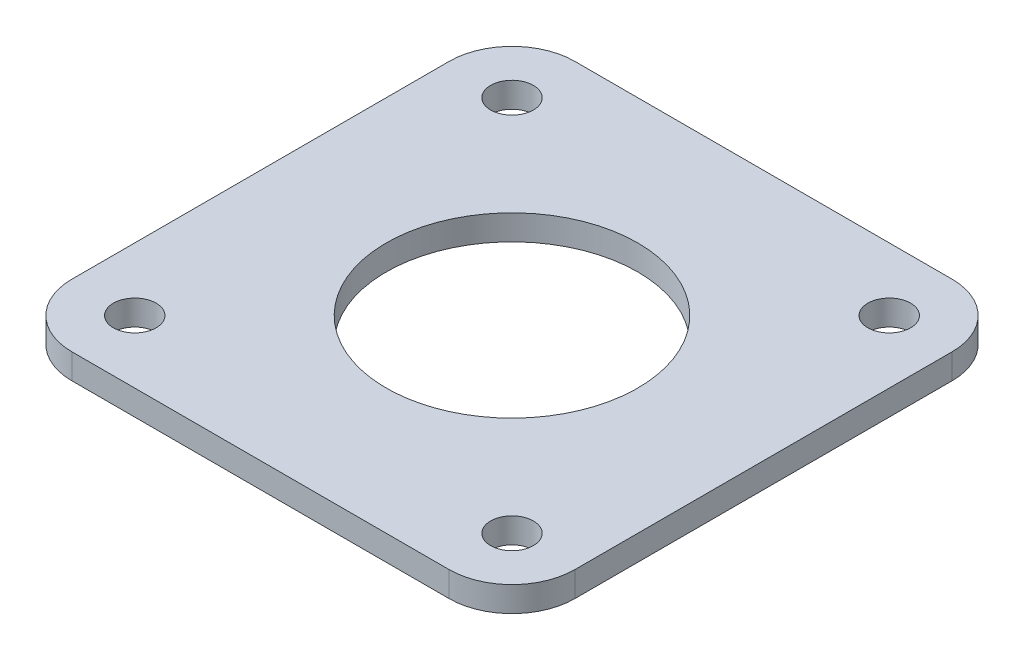
from build123d import *

# Parameters (mm, degrees)
SKETCH1_R           = 1.7
SKETCH1_R_2         = 10
BOSS_EXTRUDE1_DEPTH = 2


with BuildPart() as part:
    # Sketch1 → Boss-Extrude1 (new body)
    with BuildSketch(Plane.XZ.offset(3)):
        with BuildLine():
            Line((-15, -20), (15, -20))
            ThreePointArc((15, -20), (18.535533906, -18.535533906), (20, -15))
            Line((20, -15), (20, 15))
            ThreePointArc((20, 15), (18.535533906, 18.535533906), (15, 20))
            Line((15, 20), (-15, 20))
            ThreePointArc((-15, 20), (-18.535533906, 18.535533906), (-20, 15))
            Line((-20, 15), (-20, -15))
            ThreePointArc((-20, -15), (-18.535533906, -18.535533906), (-15, -20))
        make_face()
        with Locations((15, -15)):
            Circle(SKETCH1_R, mode=Mode.SUBTRACT)
        with Locations((-15, -15)):
            Circle(SKETCH1_R, mode=Mode.SUBTRACT)
        with Locations((15, 15)):
            Circle(SKETCH1_R, mode=Mode.SUBTRACT)
        with Locations((-15, 15)):
            Circle(SKETCH1_R, mode=Mode.SUBTRACT)
        Circle(SKETCH1_R_2, mode=Mode.SUBTRACT)
    extrude(amount=BOSS_EXTRUDE1_DEPTH)


solid = part.part
